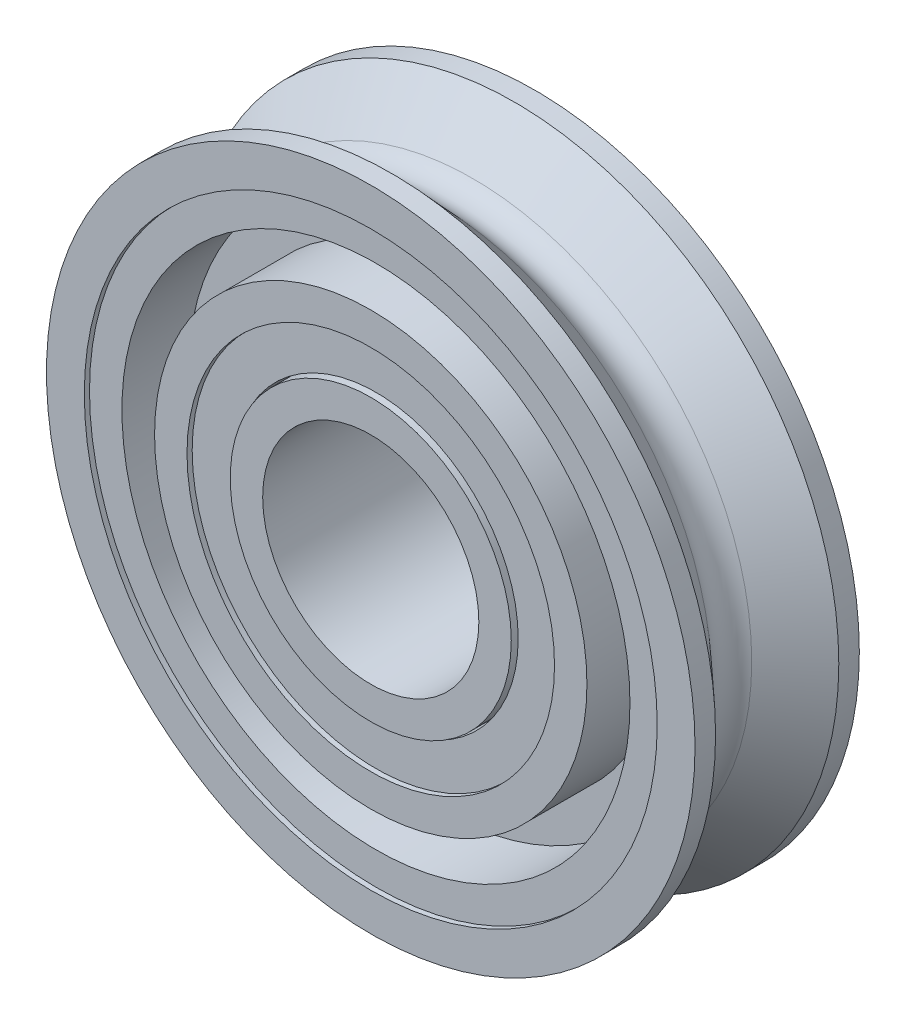
from build123d import *
from build123d.topology import SkipClean

# Parameters (mm, degrees)
CUT_EXTRUDE_THIN1_DEPTH      = 7.842401242
CUT_EXTRUDE_THIN1_DEPTH_BACK = 7.842401242
SKETCH2_R                    = 2.08915
SKETCH2_R_2                  = 2.06375


with BuildPart() as part:
    # Sketch1 → Revolve1 (revolve)
    with BuildSketch(Plane(origin=(0, 0, 0), x_dir=(0, 0, -1), z_dir=(1, 0, 0))):
        with BuildLine():
            Line((0.904875, 4.7625), (1.2065, 4.7625))
            Line((1.2065, 4.7625), (1.2065, 4.206875))
            Line((1.2065, 4.206875), (1.1303, 4.206875))
            Line((1.1303, 4.206875), (1.1303, 3.730625))
            Line((1.1303, 3.730625), (0.1508125, 3.730625))
            Line((0.1508125, 3.730625), (0.1508125, 3.175))
            Line((0.1508125, 3.175), (1.2065, 3.175))
            Line((1.2065, 3.175), (1.2065, 2.69875))
            Line((1.2065, 2.69875), (1.1303, 2.69875))
            Line((1.1303, 2.69875), (1.1303, 2.06375))
            Line((1.1303, 2.06375), (1.2065, 2.06375))
            Line((1.2065, 2.06375), (1.2065, 1.5875))
            Line((1.2065, 1.5875), (-1.2065, 1.5875))
            Line((-1.2065, 1.5875), (-1.2065, 2.06375))
            Line((-1.2065, 2.06375), (-1.1303, 2.06375))
            Line((-1.1303, 2.06375), (-1.1303, 2.69875))
            Line((-1.1303, 2.69875), (-1.2065, 2.69875))
            Line((-1.2065, 2.69875), (-1.2065, 3.175))
            Line((-1.2065, 3.175), (-0.1508125, 3.175))
            Line((-0.1508125, 3.175), (-0.1508125, 3.730625))
            Line((-0.1508125, 3.730625), (-1.1303, 3.730625))
            Line((-1.1303, 3.730625), (-1.1303, 4.206875))
            Line((-1.1303, 4.206875), (-1.2065, 4.206875))
            Line((-1.2065, 4.206875), (-1.2065, 4.7625))
            Line((-1.2065, 4.7625), (-0.904875, 4.7625))
            Line((-0.904875, 4.7625), (-0.291970509, 4.096807241))
            ThreePointArc((-0.291970509, 4.096807241), (0, 3.96875), (0.291970509, 4.096807241))
            Line((0.291970509, 4.096807241), (0.904875, 4.7625))
        make_face()
    revolve(axis=Axis((0, 0, 1.2065), (0, 0, -1)))

    # Sketch2 → Cut-Extrude-Thin1 (cut, two sides: drawn at the far end of the back side and taken through both)
    with SkipClean():  # the faces are left unmerged after this step: merging them gives an invalid solid
        with BuildSketch(Plane.XY.offset(-CUT_EXTRUDE_THIN1_DEPTH_BACK)):
            Circle(SKETCH2_R)
            Circle(SKETCH2_R_2, mode=Mode.SUBTRACT)
        extrude(amount=CUT_EXTRUDE_THIN1_DEPTH + CUT_EXTRUDE_THIN1_DEPTH_BACK, mode=Mode.SUBTRACT)


with BuildPart() as cut_extrude_thin1_piece_1:
    # of the separate pieces the step leaves, piece 1, a body of its own (cut_extrude_thin1_pieces)
    add(part.part.solids().sort_by_distance((0, 4.096807241, 0.291970509))[0])


with BuildPart() as cut_extrude_thin1_piece_2:
    # of the separate pieces the step leaves, piece 2, a body of its own (cut_extrude_thin1_pieces)
    add(part.part.solids().sort_by_distance((0, 2.06375, 1.2065))[0])


solid = Compound([cut_extrude_thin1_piece_1.part, cut_extrude_thin1_piece_2.part])
